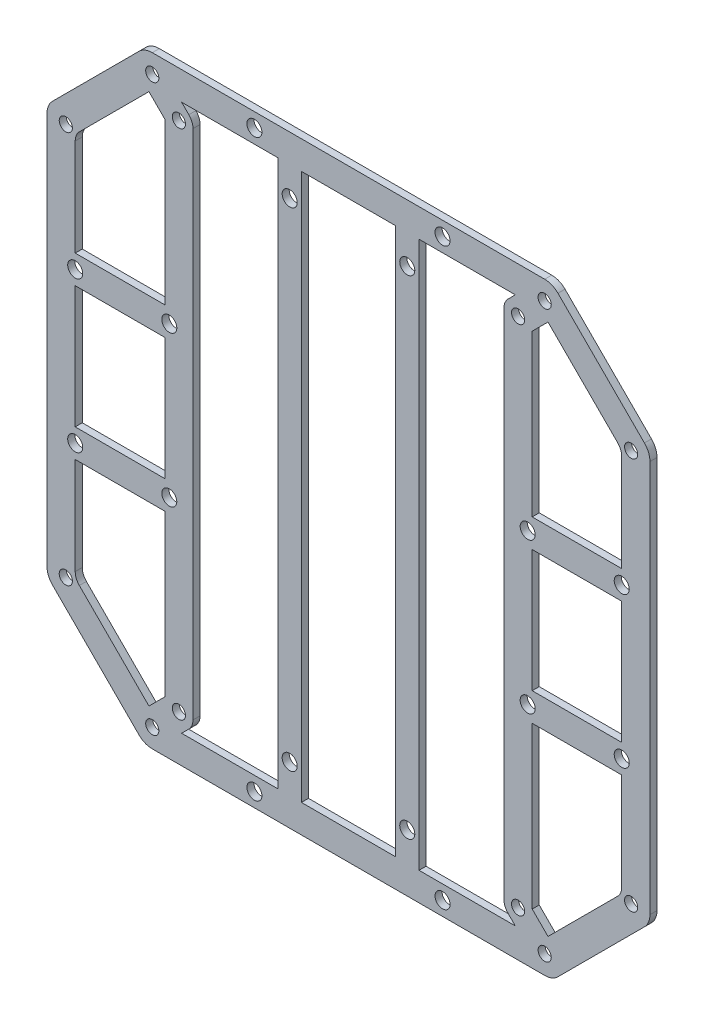
from build123d import *

# Parameters (mm, degrees)
SKETCH1_R            = 1.6
SKETCH1_R_2          = 1.4
SKETCH1_R_3          = 56
BOSS_EXTRUDE13_DEPTH = 1.5
FILLET2_R            = 2
SKETCH2_R            = 149.802009174
CUT_EXTRUDE1_DEPTH   = 10
BOSS_EXTRUDE14_DEPTH = 1.5
CUT_EXTRUDE2_DEPTH   = 10
SKETCH5_R            = 1.6
CUT_EXTRUDE4_DEPTH   = 10
SKETCH6_R            = 61
CUT_EXTRUDE5_DEPTH   = 10
BOSS_EXTRUDE15_DEPTH = 1.5
SKETCH8_R            = 1.6
CUT_EXTRUDE6_DEPTH   = 10
BOSS_EXTRUDE16_DEPTH = 1.5
SKETCH10_R           = 1.829976552
SKETCH10_R_2         = 1.480071825
SKETCH10_R_3         = 1.153481382
SKETCH10_R_4         = 1.138729051
BOSS_EXTRUDE17_DEPTH = 1.5
CUT_EXTRUDE7_DEPTH   = 10
BOSS_EXTRUDE18_DEPTH = 1.5
SKETCH13_R           = 1.6
BOSS_EXTRUDE19_DEPTH = 1.5
SKETCH14_R           = 1.6
CUT_EXTRUDE8_DEPTH   = 10
CUT_EXTRUDE9_DEPTH   = 10
FILLET3_R            = 3
SKETCH16_W           = 5
SKETCH16_H           = 116.208152802
BOSS_EXTRUDE20_DEPTH = 1.5
SKETCH17_R           = 1.6
CUT_EXTRUDE10_DEPTH  = 1.5
SKETCH18_R           = 1.6
CUT_EXTRUDE12_DEPTH  = 4


with BuildPart() as part:
    # Sketch1 → Boss-Extrude13 (new body)
    with BuildSketch(Plane.XY):
        with BuildLine():
            Line((35.888794811, 73.41211972), (-35.888794811, 73.41211972))
            Line((-35.888794811, 73.41211972), (-35.888794811, 92.265889727))
            ThreePointArc((-35.888794811, 92.265889727), (-42.061063674, 89.620683565), (-48.039811225, 86.563136135))
            Line((-48.039811225, 86.563136135), (-41.888794811, 80.41211972))
            Line((-41.888794811, 80.41211972), (-41.888794811, 65.59143593))
            Line((-41.888794811, 65.59143593), (-53.74011537, 53.74011537))
            Line((-53.74011537, 53.74011537), (-65.053823869, 42.426406871))
            Line((-65.053823869, 42.426406871), (-74.835892241, 32.6443385))
            Line((-74.835892241, 32.6443385), (-84.884227212, 42.692673471))
            ThreePointArc((-84.884227212, 42.692673471), (-87.526492089, 43.525776386), (-89.724470917, 41.839207912))
            ThreePointArc((-89.724470917, 41.839207912), (-99, 0), (-89.724470917, -41.839207912))
            ThreePointArc((-89.724470917, -41.839207912), (-87.526492089, -43.525776386), (-84.884227212, -42.692673471))
            Line((-84.884227212, -42.692673471), (-83.381153952, -41.189600211))
            Line((-83.381153952, -41.189600211), (-74.835892241, -32.6443385))
            Line((-74.835892241, -32.6443385), (-65.053823869, -42.426406871))
            Line((-65.053823869, -42.426406871), (-53.74011537, -53.74011537))
            Line((-53.74011537, -53.74011537), (-41.888794811, -65.59143593))
            Line((-41.888794811, -65.59143593), (-41.888794811, -80.41211972))
            Line((-41.888794811, -80.41211972), (-48.039811225, -86.563136135))
            ThreePointArc((-48.039811225, -86.563136135), (-42.061063674, -89.620683565), (-35.888794811, -92.265889727))
            Line((-35.888794811, -92.265889727), (-35.888794811, -73.41211972))
            Line((-35.888794811, -73.41211972), (35.888794811, -73.41211972))
            Line((35.888794811, -73.41211972), (35.888794811, -92.265889727))
            ThreePointArc((35.888794811, -92.265889727), (42.061063674, -89.620683565), (48.039811225, -86.563136135))
            Line((48.039811225, -86.563136135), (41.888794811, -80.41211972))
            Line((41.888794811, -80.41211972), (41.888794811, -65.59143593))
            Line((41.888794811, -65.59143593), (53.74011537, -53.74011537))
            Line((53.74011537, -53.74011537), (65.053823869, -42.426406871))
            Line((65.053823869, -42.426406871), (74.835892241, -32.6443385))
            Line((74.835892241, -32.6443385), (83.381153952, -41.189600211))
            Line((83.381153952, -41.189600211), (84.884227212, -42.692673471))
            ThreePointArc((84.884227212, -42.692673471), (87.526492089, -43.525776386), (89.724470917, -41.839207912))
            ThreePointArc((89.724470917, -41.839207912), (99, 0), (89.724470917, 41.839207912))
            ThreePointArc((89.724470917, 41.839207912), (87.526492089, 43.525776386), (84.884227212, 42.692673471))
            Line((84.884227212, 42.692673471), (74.835892241, 32.6443385))
            Line((74.835892241, 32.6443385), (65.053823869, 42.426406871))
            Line((65.053823869, 42.426406871), (53.74011537, 53.74011537))
            Line((53.74011537, 53.74011537), (41.888794811, 65.59143593))
            Line((41.888794811, 65.59143593), (41.888794811, 80.41211972))
            Line((41.888794811, 80.41211972), (48.039811225, 86.563136135))
            ThreePointArc((48.039811225, 86.563136135), (42.061063674, 89.620683565), (35.888794811, 92.265889727))
            Line((35.888794811, 92.265889727), (35.888794811, 73.41211972))
        make_face()
        with Locations((-40.571353127, -87.005547556)):
            Circle(SKETCH1_R, mode=Mode.SUBTRACT)
        with Locations((-41.71930009, -60.104076401)):
            Circle(SKETCH1_R_2, mode=Mode.SUBTRACT)
        with Locations((-36.062445841, -54.447222151)):
            Circle(SKETCH1_R_2, mode=Mode.SUBTRACT)
        with Locations((-87.005547556, -40.571353127)):
            Circle(SKETCH1_R, mode=Mode.SUBTRACT)
        with Locations((-60.104076401, -41.71930009)):
            Circle(SKETCH1_R_2, mode=Mode.SUBTRACT)
        with Locations((-54.447222151, -36.062445841)):
            Circle(SKETCH1_R_2, mode=Mode.SUBTRACT)
        with BuildLine():
            Line((-35.478902811, -49.621038435), (-42.426406871, -56.568542495))
            Line((-42.426406871, -56.568542495), (-56.568542495, -42.426406871))
            Line((-56.568542495, -42.426406871), (-49.621038435, -35.478902811))
            ThreePointArc((-49.621038435, -35.478902811), (-43.133513652, -43.133513652), (-35.478902811, -49.621038435))
        make_face(mode=Mode.SUBTRACT)
        with Locations((-41.365746699, -41.365746699)):
            Circle(SKETCH1_R, mode=Mode.SUBTRACT)
        with Locations((40.571353127, -87.005547556)):
            Circle(SKETCH1_R, mode=Mode.SUBTRACT)
        with BuildLine():
            Line((35.888794811, -67.41211972), (0, -67.41211972))
            Line((0, -67.41211972), (-35.888794811, -67.41211972))
            Line((-35.888794811, -67.41211972), (-35.888794811, -58.516211808))
            Line((-35.888794811, -58.516211808), (-30.309602278, -52.937019275))
            ThreePointArc((-30.309602278, -52.937019275), (0, -61), (30.309602278, -52.937019275))
            Line((30.309602278, -52.937019275), (35.888794811, -58.516211808))
            Line((35.888794811, -58.516211808), (35.888794811, -67.41211972))
        make_face(mode=Mode.SUBTRACT)
        with Locations((41.71930009, -60.104076401)):
            Circle(SKETCH1_R_2, mode=Mode.SUBTRACT)
        with Locations((36.062445841, -54.447222151)):
            Circle(SKETCH1_R_2, mode=Mode.SUBTRACT)
        with Locations((41.365746699, -41.365746699)):
            Circle(SKETCH1_R, mode=Mode.SUBTRACT)
        with BuildLine():
            Line((49.621038435, -35.478902811), (56.568542495, -42.426406871))
            Line((56.568542495, -42.426406871), (42.426406871, -56.568542495))
            Line((42.426406871, -56.568542495), (35.478902811, -49.621038435))
            ThreePointArc((35.478902811, -49.621038435), (43.133513652, -43.133513652), (49.621038435, -35.478902811))
        make_face(mode=Mode.SUBTRACT)
        Circle(SKETCH1_R_3, mode=Mode.SUBTRACT)
        with Locations((60.104076401, -41.71930009)):
            Circle(SKETCH1_R_2, mode=Mode.SUBTRACT)
        with Locations((54.447222151, -36.062445841)):
            Circle(SKETCH1_R_2, mode=Mode.SUBTRACT)
        with Locations((87.005547556, -40.571353127)):
            Circle(SKETCH1_R, mode=Mode.SUBTRACT)
        with BuildLine():
            ThreePointArc((86.037232719, 35.307146387), (93, 0), (86.037232719, -35.307146387))
            Line((86.037232719, -35.307146387), (74.957719555, -24.037229811))
            Line((74.957719555, -24.037229811), (60.811183182, -38.183766184))
            Line((60.811183182, -38.183766184), (57.337431152, -34.710014154))
            Line((57.337431152, -34.710014154), (52.937019276, -30.309602278))
            ThreePointArc((52.937019276, -30.309602278), (61, 0), (52.937019276, 30.309602278))
            Line((52.937019276, 30.309602278), (57.337431152, 34.710014154))
            Line((57.337431152, 34.710014154), (60.811183182, 38.183766184))
            Line((60.811183182, 38.183766184), (74.957719555, 24.037229811))
            Line((74.957719555, 24.037229811), (86.037232719, 35.307146387))
        make_face(mode=Mode.SUBTRACT)
        with BuildLine():
            Line((-74.957719555, -24.037229811), (-86.037232719, -35.307146387))
            ThreePointArc((-86.037232719, -35.307146387), (-93, 0), (-86.037232719, 35.307146387))
            Line((-86.037232719, 35.307146387), (-74.957719555, 24.037229811))
            Line((-74.957719555, 24.037229811), (-60.811183182, 38.183766184))
            Line((-60.811183182, 38.183766184), (-57.337431152, 34.710014154))
            Line((-57.337431152, 34.710014154), (-52.937019276, 30.309602278))
            ThreePointArc((-52.937019276, 30.309602278), (-61, 0), (-52.937019276, -30.309602278))
            Line((-52.937019276, -30.309602278), (-57.337431152, -34.710014154))
            Line((-57.337431152, -34.710014154), (-60.811183182, -38.183766184))
            Line((-60.811183182, -38.183766184), (-74.957719555, -24.037229811))
        make_face(mode=Mode.SUBTRACT)
        with Locations((-87.005547556, 40.571353127)):
            Circle(SKETCH1_R, mode=Mode.SUBTRACT)
        with Locations((-54.447222151, 36.062445841)):
            Circle(SKETCH1_R_2, mode=Mode.SUBTRACT)
        with Locations((-60.104076401, 41.71930009)):
            Circle(SKETCH1_R_2, mode=Mode.SUBTRACT)
        with BuildLine():
            Line((-49.621038435, 35.478902811), (-56.568542495, 42.426406871))
            Line((-56.568542495, 42.426406871), (-42.426406871, 56.568542495))
            Line((-42.426406871, 56.568542495), (-35.478902811, 49.621038435))
            ThreePointArc((-35.478902811, 49.621038435), (-43.133513652, 43.133513652), (-49.621038435, 35.478902811))
        make_face(mode=Mode.SUBTRACT)
        with Locations((-41.365746699, 41.365746699)):
            Circle(SKETCH1_R, mode=Mode.SUBTRACT)
        with Locations((-36.062445841, 54.447222151)):
            Circle(SKETCH1_R_2, mode=Mode.SUBTRACT)
        with Locations((-41.71930009, 60.104076401)):
            Circle(SKETCH1_R_2, mode=Mode.SUBTRACT)
        with Locations((-40.571353127, 87.005547556)):
            Circle(SKETCH1_R, mode=Mode.SUBTRACT)
        with Locations((41.365746699, 41.365746699)):
            Circle(SKETCH1_R, mode=Mode.SUBTRACT)
        with BuildLine():
            Line((35.478902811, 49.621038435), (42.426406871, 56.568542495))
            Line((42.426406871, 56.568542495), (56.568542495, 42.426406871))
            Line((56.568542495, 42.426406871), (49.621038435, 35.478902811))
            ThreePointArc((49.621038435, 35.478902811), (43.133513652, 43.133513652), (35.478902811, 49.621038435))
        make_face(mode=Mode.SUBTRACT)
        with Locations((54.447222151, 36.062445841)):
            Circle(SKETCH1_R_2, mode=Mode.SUBTRACT)
        with Locations((60.104076401, 41.71930009)):
            Circle(SKETCH1_R_2, mode=Mode.SUBTRACT)
        with Locations((87.005547556, 40.571353127)):
            Circle(SKETCH1_R, mode=Mode.SUBTRACT)
        with BuildLine():
            Line((-35.888794811, 58.516211808), (-35.888794811, 67.41211972))
            Line((-35.888794811, 67.41211972), (0, 67.41211972))
            Line((0, 67.41211972), (35.888794811, 67.41211972))
            Line((35.888794811, 67.41211972), (35.888794811, 58.516211808))
            Line((35.888794811, 58.516211808), (30.309602278, 52.937019275))
            ThreePointArc((30.309602278, 52.937019275), (0, 61), (-30.309602278, 52.937019275))
            Line((-30.309602278, 52.937019275), (-35.888794811, 58.516211808))
        make_face(mode=Mode.SUBTRACT)
        with Locations((36.062445841, 54.447222151)):
            Circle(SKETCH1_R_2, mode=Mode.SUBTRACT)
        with Locations((41.71930009, 60.104076401)):
            Circle(SKETCH1_R_2, mode=Mode.SUBTRACT)
        with Locations((40.571353127, 87.005547556)):
            Circle(SKETCH1_R, mode=Mode.SUBTRACT)
    extrude(amount=BOSS_EXTRUDE13_DEPTH)

    # Fillet2
    fillet2_edges = [part.edges().sort_by_distance(p)[0] for p in [
        (-48.039811225, 86.563136135, 0.75),
        (-35.888794811, 92.265889727, 0.75),
        (35.888794811, 92.265889727, 0.75),
        (48.039811225, 86.563136135, 0.75),
        (48.039811225, -86.563136135, 0.75),
        (35.888794811, -92.265889727, 0.75),
        (-35.888794811, -92.265889727, 0.75),
        (-48.039811225, -86.563136135, 0.75),
    ]]
    fillet(fillet2_edges, radius=FILLET2_R)

    # Sketch2 → Cut-Extrude1 (cut)
    with BuildSketch(Plane.XY.offset(1.5)):
        Circle(SKETCH2_R)
        with BuildLine():
            Line((-41.71930009, 64.104076401), (41.71930009, 64.104076401))
            ThreePointArc((41.71930009, 64.104076401), (43.250033819, 63.799594531), (44.547727215, 62.932503526))
            Line((44.547727215, 62.932503526), (62.932503526, 44.547727215))
            ThreePointArc((62.932503526, 44.547727215), (63.799594531, 43.250033819), (64.104076401, 41.71930009))
            Line((64.104076401, 41.71930009), (64.104076401, -41.71930009))
            ThreePointArc((64.104076401, -41.71930009), (63.799594531, -43.250033819), (62.932503526, -44.547727215))
            Line((62.932503526, -44.547727215), (44.547727215, -62.932503526))
            ThreePointArc((44.547727215, -62.932503526), (43.250033819, -63.799594531), (41.71930009, -64.104076401))
            Line((41.71930009, -64.104076401), (-41.71930009, -64.104076401))
            ThreePointArc((-41.71930009, -64.104076401), (-43.250033819, -63.799594531), (-44.547727215, -62.932503526))
            Line((-44.547727215, -62.932503526), (-62.932503526, -44.547727215))
            ThreePointArc((-62.932503526, -44.547727215), (-63.799594531, -43.250033819), (-64.104076401, -41.71930009))
            Line((-64.104076401, -41.71930009), (-64.104076401, 41.71930009))
            ThreePointArc((-64.104076401, 41.71930009), (-63.799594531, 43.250033819), (-62.932503526, 44.547727215))
            Line((-62.932503526, 44.547727215), (-44.547727215, 62.932503526))
            ThreePointArc((-44.547727215, 62.932503526), (-43.250033819, 63.799594531), (-41.71930009, 64.104076401))
        make_face(mode=Mode.SUBTRACT)
    extrude(amount=-CUT_EXTRUDE1_DEPTH, mode=Mode.SUBTRACT)

    # Sketch3 → Boss-Extrude14 (add)
    with BuildSketch(Plane.XY.offset(1.5)):
        with BuildLine():
            Line((-56.104076401, -41.71930009), (-56.104076401, 41.71930009))
            ThreePointArc((-56.104076401, 41.71930009), (-60.104076401, 37.71930009), (-64.104076401, 41.71930009))
            Line((-64.104076401, 41.71930009), (-64.104076401, -41.71930009))
            ThreePointArc((-64.104076401, -41.71930009), (-60.104076401, -37.71930009), (-56.104076401, -41.71930009))
        make_face()
        with BuildLine():
            Line((-41.71930009, -64.104076401), (41.71930009, -64.104076401))
            ThreePointArc((41.71930009, -64.104076401), (37.71930009, -60.104076401), (41.71930009, -56.104076401))
            Line((41.71930009, -56.104076401), (-41.71930009, -56.104076401))
            ThreePointArc((-41.71930009, -56.104076401), (-37.71930009, -60.104076401), (-41.71930009, -64.104076401))
        make_face()
        with BuildLine():
            Line((56.104076401, 41.71930009), (56.104076401, -41.71930009))
            ThreePointArc((56.104076401, -41.71930009), (60.104076401, -37.71930009), (64.104076401, -41.71930009))
            Line((64.104076401, -41.71930009), (64.104076401, 41.71930009))
            ThreePointArc((64.104076401, 41.71930009), (60.104076401, 37.71930009), (56.104076401, 41.71930009))
        make_face()
        with BuildLine():
            Line((-41.71930009, 64.104076401), (41.71930009, 64.104076401))
            ThreePointArc((41.71930009, 64.104076401), (37.71930009, 60.104076401), (41.71930009, 56.104076401))
            Line((41.71930009, 56.104076401), (-41.71930009, 56.104076401))
            ThreePointArc((-41.71930009, 56.104076401), (-37.71930009, 60.104076401), (-41.71930009, 64.104076401))
        make_face()
    extrude(amount=-BOSS_EXTRUDE14_DEPTH)

    # Sketch4 → Cut-Extrude2 (cut)
    with BuildSketch(Plane(origin=(0, 0, 0), x_dir=(-1, 0, 0), z_dir=(0, 0, -1))):
        with BuildLine():
            ThreePointArc((-58.104076401, -18.571922507), (-55.829871161, -24.576929958), (-52.937019275, -30.309602278))
            Line((-52.937019275, -30.309602278), (-58.104076401, -35.476659403))
            Line((-58.104076401, -35.476659403), (-58.104076401, -18.571922507))
        make_face()
        with BuildLine():
            Line((-18.571922507, -58.104076401), (-35.476659403, -58.104076401))
            Line((-35.476659403, -58.104076401), (-30.309602278, -52.937019275))
            ThreePointArc((-30.309602278, -52.937019275), (-24.576929958, -55.829871161), (-18.571922507, -58.104076401))
        make_face()
        with BuildLine():
            ThreePointArc((18.571922507, -58.104076401), (24.576929958, -55.829871161), (30.309602278, -52.937019275))
            Line((30.309602278, -52.937019275), (35.476659403, -58.104076401))
            Line((35.476659403, -58.104076401), (18.571922507, -58.104076401))
        make_face()
        with BuildLine():
            Line((58.104076401, -18.571922507), (58.104076401, -35.476659403))
            Line((58.104076401, -35.476659403), (52.937019275, -30.309602278))
            ThreePointArc((52.937019275, -30.309602278), (55.829871161, -24.576929958), (58.104076401, -18.571922507))
        make_face()
        with BuildLine():
            ThreePointArc((58.104076401, 18.571922507), (55.829871161, 24.576929958), (52.937019275, 30.309602278))
            Line((52.937019275, 30.309602278), (58.104076401, 35.476659403))
            Line((58.104076401, 35.476659403), (58.104076401, 18.571922507))
        make_face()
        with BuildLine():
            ThreePointArc((-18.571922507, 58.104076401), (-24.576929958, 55.829871161), (-30.309602278, 52.937019275))
            Line((-30.309602278, 52.937019275), (-35.476659403, 58.104076401))
            Line((-35.476659403, 58.104076401), (-18.571922507, 58.104076401))
        make_face()
        with BuildLine():
            Line((-58.104076401, 18.571922507), (-58.104076401, 35.476659403))
            Line((-58.104076401, 35.476659403), (-52.937019275, 30.309602278))
            ThreePointArc((-52.937019275, 30.309602278), (-55.829871161, 24.576929958), (-58.104076401, 18.571922507))
        make_face()
        with BuildLine():
            Line((18.571922507, 58.104076401), (35.476659403, 58.104076401))
            Line((35.476659403, 58.104076401), (30.309602278, 52.937019275))
            ThreePointArc((30.309602278, 52.937019275), (24.576929958, 55.829871161), (18.571922507, 58.104076401))
        make_face()
    extrude(amount=-CUT_EXTRUDE2_DEPTH, mode=Mode.SUBTRACT)

    # Sketch5 → Cut-Extrude4 (cut)
    with BuildSketch(Plane(origin=(0, 0, 0), x_dir=(-1, 0, 0), z_dir=(0, 0, -1))):
        with Locations((-22, 58.104076401)):
            Circle(SKETCH5_R)
        with Locations((22, 58.104076401)):
            Circle(SKETCH5_R)
        with Locations((22, -58.104076401)):
            Circle(SKETCH5_R)
        with Locations((-22, -58.104076401)):
            Circle(SKETCH5_R)
    extrude(amount=-CUT_EXTRUDE4_DEPTH, mode=Mode.SUBTRACT)

    # Sketch6 → Cut-Extrude5 (cut)
    with BuildSketch(Plane(origin=(0, 0, 0), x_dir=(-1, 0, 0), z_dir=(0, 0, -1))):
        Circle(SKETCH6_R)
    extrude(amount=-CUT_EXTRUDE5_DEPTH, mode=Mode.SUBTRACT)

    # Sketch7 → Boss-Extrude15 (add)
    with BuildSketch(Plane.XY.offset(1.5)):
        Polygon((-58.104076401, 18.571922507), (-58.104076401, -18.571922507), (-62.424628758, -11.335451354), (-62.424628758, 6.634309606), align=None)
        Polygon((-18.571922507, 58.104076401), (18.571922507, 58.104076401), (11.104699249, 62.193876654), (-9.982265142, 62.193876654), align=None)
        Polygon((58.104076401, 18.571922507), (58.104076401, -18.571922507), (62.067493662, -11.335451354), (62.067493662, 12.603116056), align=None)
        Polygon((-18.571922507, -58.104076401), (18.571922507, -58.104076401), (9.271623778, -62.53223488), (-14.277093824, -62.53223488), align=None)
    extrude(amount=-BOSS_EXTRUDE15_DEPTH)

    # Sketch8 → Cut-Extrude6 (cut)
    with BuildSketch(Plane.XY.offset(1.5)):
        with Locations((-58.104076401, 16)):
            Circle(SKETCH8_R)
        with Locations((-58.104076401, -16)):
            Circle(SKETCH8_R)
        with Locations((58.104076401, -16)):
            Circle(SKETCH8_R)
        with Locations((58.104076401, 16)):
            Circle(SKETCH8_R)
    extrude(amount=-CUT_EXTRUDE6_DEPTH, mode=Mode.SUBTRACT)

    # Sketch9 → Boss-Extrude16 (add)
    with BuildSketch(Plane.XY.offset(1.5)):
        with BuildLine():
            Line((-23.6, -58.104076401), (-20.4, -58.104076401))
            ThreePointArc((-20.4, -58.104076401), (-22, -59.704076401), (-23.6, -58.104076401))
        make_face()
        with BuildLine():
            Line((23.6, 58.104076401), (20.4, 58.104076401))
            ThreePointArc((20.4, 58.104076401), (22, 59.704076401), (23.6, 58.104076401))
        make_face()
        with BuildLine():
            Line((-20.4, 58.104076401), (-23.6, 58.104076401))
            ThreePointArc((-23.6, 58.104076401), (-22, 59.704076401), (-20.4, 58.104076401))
        make_face()
        with BuildLine():
            Line((20.4, -58.104076401), (23.6, -58.104076401))
            ThreePointArc((23.6, -58.104076401), (22, -59.704076401), (20.4, -58.104076401))
        make_face()
    extrude(amount=-BOSS_EXTRUDE16_DEPTH)

    # Sketch10 → Boss-Extrude17 (add)
    with BuildSketch(Plane.XY.offset(1.5)):
        with Locations((-61.845873387, 37.792274243)):
            Circle(SKETCH10_R)
        with Locations((-60.969247638, -37.335662924)):
            Circle(SKETCH10_R_2)
        with Locations((60.718783259, -37.335662924)):
            Circle(SKETCH10_R_3)
        with Locations((60.284772511, 38.1877284)):
            Circle(SKETCH10_R_4)
    extrude(amount=-BOSS_EXTRUDE17_DEPTH)

    # Sketch11 → Cut-Extrude7 (cut)
    with BuildSketch(Plane.XY.offset(1.5)):
        with BuildLine():
            ThreePointArc((-52.325901808, -38.183766184), (-52.325901808, -33.941125497), (-56.568542495, -33.941125497))
            Line((-56.568542495, -33.941125497), (-53.386757218, -23.257215487))
            Line((-53.386757218, -23.257215487), (-49.487034753, -23.257215487))
            Line((-49.487034753, -23.257215487), (-44.572661254, -30.683266679))
            Line((-44.572661254, -30.683266679), (-47.927145767, -40.935957329))
            Line((-47.927145767, -40.935957329), (-52.325901808, -38.183766184))
        make_face()
        with BuildLine():
            Line((-38.183766184, -52.325901808), (-40.935957329, -47.927145767))
            Line((-40.935957329, -47.927145767), (-30.683266679, -44.572661254))
            Line((-30.683266679, -44.572661254), (-23.257215487, -49.487034753))
            Line((-23.257215487, -49.487034753), (-23.257215487, -53.386757218))
            Line((-23.257215487, -53.386757218), (-33.941125497, -56.568542495))
            ThreePointArc((-33.941125497, -56.568542495), (-33.941125497, -52.325901808), (-38.183766184, -52.325901808))
        make_face()
        with BuildLine():
            ThreePointArc((38.183766184, -52.325901808), (33.941125497, -52.325901808), (33.941125497, -56.568542495))
            Line((33.941125497, -56.568542495), (23.257215487, -53.386757218))
            Line((23.257215487, -53.386757218), (23.257215487, -49.487034753))
            Line((23.257215487, -49.487034753), (30.683266679, -44.572661254))
            Line((30.683266679, -44.572661254), (40.935957329, -47.927145767))
            Line((40.935957329, -47.927145767), (38.183766184, -52.325901808))
        make_face()
        with BuildLine():
            ThreePointArc((56.568542495, -33.941125497), (52.325901808, -33.941125497), (52.325901808, -38.183766184))
            Line((52.325901808, -38.183766184), (47.927145767, -40.935957329))
            Line((47.927145767, -40.935957329), (44.572661254, -30.683266679))
            Line((44.572661254, -30.683266679), (49.487034753, -23.257215487))
            Line((49.487034753, -23.257215487), (53.386757218, -23.257215487))
            Line((53.386757218, -23.257215487), (56.568542495, -33.941125497))
        make_face()
        with BuildLine():
            ThreePointArc((52.325901808, 38.183766184), (52.325901808, 33.941125497), (56.568542495, 33.941125497))
            Line((56.568542495, 33.941125497), (53.386757218, 23.257215487))
            Line((53.386757218, 23.257215487), (49.487034753, 23.257215487))
            Line((49.487034753, 23.257215487), (44.572661254, 30.683266679))
            Line((44.572661254, 30.683266679), (47.927145767, 40.935957329))
            Line((47.927145767, 40.935957329), (52.325901808, 38.183766184))
        make_face()
        with BuildLine():
            Line((38.183766184, 52.325901808), (40.935957329, 47.927145767))
            Line((40.935957329, 47.927145767), (30.683266679, 44.572661254))
            Line((30.683266679, 44.572661254), (23.257215487, 49.487034753))
            Line((23.257215487, 49.487034753), (23.257215487, 53.386757218))
            Line((23.257215487, 53.386757218), (33.941125497, 56.568542495))
            ThreePointArc((33.941125497, 56.568542495), (33.941125497, 52.325901808), (38.183766184, 52.325901808))
        make_face()
        with BuildLine():
            ThreePointArc((-38.183766184, 52.325901808), (-33.941125497, 52.325901808), (-33.941125497, 56.568542495))
            Line((-33.941125497, 56.568542495), (-23.257215487, 53.386757218))
            Line((-23.257215487, 53.386757218), (-23.257215487, 49.487034753))
            Line((-23.257215487, 49.487034753), (-30.683266679, 44.572661254))
            Line((-30.683266679, 44.572661254), (-40.935957329, 47.927145767))
            Line((-40.935957329, 47.927145767), (-38.183766184, 52.325901808))
        make_face()
        with BuildLine():
            ThreePointArc((-56.568542495, 33.941125497), (-52.325901808, 33.941125497), (-52.325901808, 38.183766184))
            Line((-52.325901808, 38.183766184), (-47.927145767, 40.935957329))
            Line((-47.927145767, 40.935957329), (-44.572661254, 30.683266679))
            Line((-44.572661254, 30.683266679), (-49.487034753, 23.257215487))
            Line((-49.487034753, 23.257215487), (-53.386757218, 23.257215487))
            Line((-53.386757218, 23.257215487), (-56.568542495, 33.941125497))
        make_face()
    extrude(amount=-CUT_EXTRUDE7_DEPTH, mode=Mode.SUBTRACT)

    # Sketch12 → Boss-Extrude18 (add)
    with BuildSketch(Plane(origin=(0, 0, 0), x_dir=(-1, 0, 0), z_dir=(0, 0, -1))):
        Polygon((-33.06244584, -54.447222151), (-33.06244584, 54.447222151), (-36.062445841, 52.511621563), (-39.06244584, 53.204581464), (-39.06244584, 0), (-39.06244584, -54.447222151), (-36.062445841, -52.511621563), align=None)
        Polygon((36.062445841, -52.511621563), (33.06244584, -54.447222151), (33.06244584, 54.447222151), (36.062445841, 52.511621563), (39.06244584, 53.204581464), (39.06244584, 0), (39.06244584, -54.447222151), align=None)
    extrude(amount=-BOSS_EXTRUDE18_DEPTH)

    # Sketch13 → Boss-Extrude19 (add)
    with BuildSketch(Plane.XY.offset(1.5)):
        with BuildLine():
            Line((-58.104076401, 19), (-38.104076401, 19))
            ThreePointArc((-38.104076401, 19), (-35.104076401, 16), (-38.104076401, 13))
            Line((-38.104076401, 13), (-58.104076401, 13))
            ThreePointArc((-58.104076401, 13), (-61.104076401, 16), (-58.104076401, 19))
        make_face()
        with Locations((-58.104076401, 16)):
            Circle(SKETCH13_R, mode=Mode.SUBTRACT)
        with Locations((-38.104076401, 16)):
            Circle(SKETCH13_R, mode=Mode.SUBTRACT)
        with BuildLine():
            Line((-58.104076401, -13), (-38.104076401, -13))
            ThreePointArc((-38.104076401, -13), (-35.104076401, -16), (-38.104076401, -19))
            Line((-38.104076401, -19), (-58.104076401, -19))
            ThreePointArc((-58.104076401, -19), (-61.104076401, -16), (-58.104076401, -13))
        make_face()
        with Locations((-38.104076401, -16)):
            Circle(SKETCH13_R, mode=Mode.SUBTRACT)
        with Locations((-58.104076401, -16)):
            Circle(SKETCH13_R, mode=Mode.SUBTRACT)
        with BuildLine():
            Line((58.104076401, -19), (38.104076401, -19))
            ThreePointArc((38.104076401, -19), (35.104076401, -16), (38.104076401, -13))
            Line((38.104076401, -13), (58.104076401, -13))
            ThreePointArc((58.104076401, -13), (61.104076401, -16), (58.104076401, -19))
        make_face()
        with Locations((58.104076401, -16)):
            Circle(SKETCH13_R, mode=Mode.SUBTRACT)
        with Locations((38.104076401, -16)):
            Circle(SKETCH13_R, mode=Mode.SUBTRACT)
        with BuildLine():
            Line((58.104076401, 13), (38.104076401, 13))
            ThreePointArc((38.104076401, 13), (35.104076401, 16), (38.104076401, 19))
            Line((38.104076401, 19), (58.104076401, 19))
            ThreePointArc((58.104076401, 19), (61.104076401, 16), (58.104076401, 13))
        make_face()
        with Locations((38.104076401, 16)):
            Circle(SKETCH13_R, mode=Mode.SUBTRACT)
        with Locations((58.104076401, 16)):
            Circle(SKETCH13_R, mode=Mode.SUBTRACT)
    extrude(amount=-BOSS_EXTRUDE19_DEPTH)

    # Sketch14 → Cut-Extrude8 (cut)
    with BuildSketch(Plane.XY.offset(1.5)):
        with Locations((-38.104076401, 16)):
            Circle(SKETCH14_R)
        with Locations((-38.104076401, -16)):
            Circle(SKETCH14_R)
        with Locations((38.104076401, 16)):
            Circle(SKETCH14_R)
        with Locations((38.104076401, -16)):
            Circle(SKETCH14_R)
    extrude(amount=-CUT_EXTRUDE8_DEPTH, mode=Mode.SUBTRACT)

    # Sketch15 → Cut-Extrude9 (cut)
    with BuildSketch(Plane.XY.offset(1.5)):
        Polygon((-58.104076401, 35.476659403), (-58.104076401, 40.890872965), (-56.568542495, 42.426406871), (-46.213251065, 41.059298437), (-49.522499611, 25.662396832), align=None)
        Polygon((-49.522499611, -25.662396832), (-58.104076401, -35.476659403), (-58.104076401, -40.890872965), (-56.568542495, -42.426406871), (-46.213251065, -41.059298437), align=None)
        Polygon((58.104076401, -35.476659403), (58.104076401, -40.890872965), (56.568542495, -42.426406871), (46.213251065, -41.059298437), (49.522499611, -25.662396832), align=None)
        Polygon((49.522499611, 25.662396832), (58.104076401, 35.476659403), (58.104076401, 40.890872965), (56.568542495, 42.426406871), (46.213251065, 41.059298437), align=None)
    extrude(amount=-CUT_EXTRUDE9_DEPTH, mode=Mode.SUBTRACT)

    # Fillet3
    fillet3_edges = [part.edges().sort_by_distance(p)[0] for p in [
        (58.104076401, 40.890872965, 0.75),
        (58.104076401, -40.890872965, 0.75),
        (-58.104076401, -40.890872965, 0.75),
        (-58.104076401, 40.890872965, 0.75),
    ]]
    fillet(fillet3_edges, radius=FILLET3_R)

    # Sketch16 → Boss-Extrude20 (add)
    with BuildSketch(Plane.XY.offset(1.5)):
        with Locations((12.5, 0)):
            Rectangle(SKETCH16_W, SKETCH16_H)
        with Locations((-12.5, 0)):
            Rectangle(SKETCH16_W, SKETCH16_H)
    extrude(amount=-BOSS_EXTRUDE20_DEPTH)

    # Sketch17 → Cut-Extrude10 (cut)
    with BuildSketch(Plane.XY.offset(1.5)):
        with Locations((12.5, -51.895923599)):
            Circle(SKETCH17_R)
        with Locations((-12.5, -51.895923599)):
            Circle(SKETCH17_R)
        with Locations((-12.5, 51.895923599)):
            Circle(SKETCH17_R)
        with Locations((12.5, 51.895923599)):
            Circle(SKETCH17_R)
    extrude(amount=-CUT_EXTRUDE10_DEPTH, mode=Mode.SUBTRACT)

    # Sketch18 → Cut-Extrude12 (cut)
    with BuildSketch(Plane.XY.offset(1.5)):
        with Locations((20, 61.104076401)):
            Circle(SKETCH18_R)
        with Locations((-20, 61.104076401)):
            Circle(SKETCH18_R)
        with Locations((-20, -61.104076401)):
            Circle(SKETCH18_R)
        with Locations((20, -61.104076401)):
            Circle(SKETCH18_R)
    extrude(amount=-CUT_EXTRUDE12_DEPTH, mode=Mode.SUBTRACT)


solid = part.part
